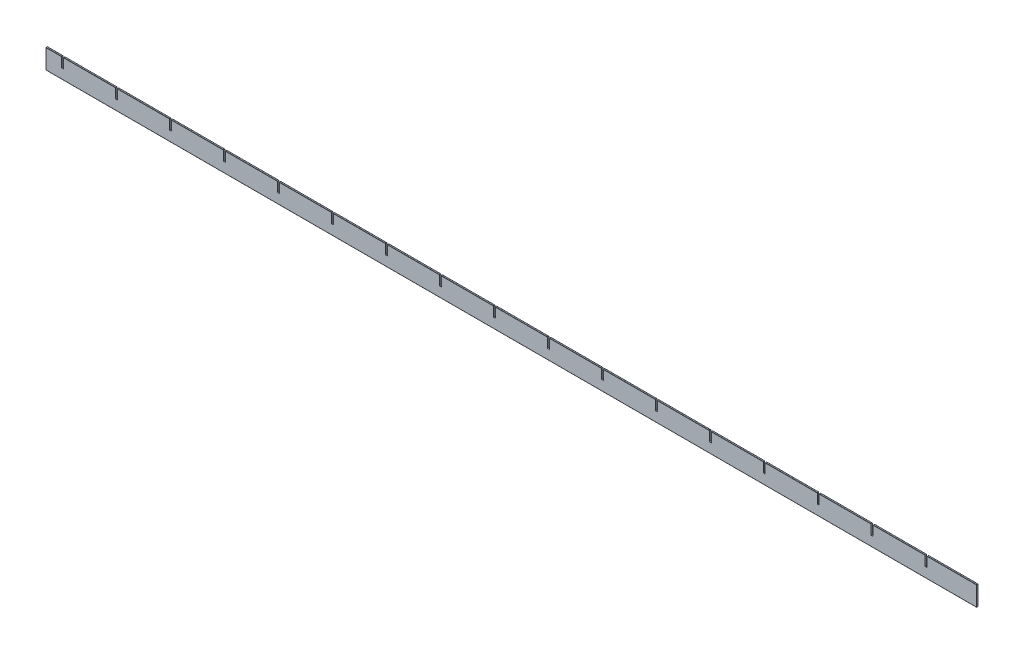
from build123d import *

# Parameters (mm, degrees)
BOSS_EXTRUDE1_DEPTH      = 1.5
BOSS_EXTRUDE1_DEPTH_BACK = 1.5
SKETCH1_W                = 1896
SKETCH1_H                = 40
FILLET1_R                = 0.35
SKETCH2_W                = 4
SKETCH2_H                = 20
CUT_EXTRUDE1_DEPTH       = 949.215692762


with BuildPart() as part:
    # Sketch1 → Boss-Extrude1 (new, two sides: drawn at the far end of the back side and taken through both)
    with BuildSketch(Plane.XY.offset(-BOSS_EXTRUDE1_DEPTH_BACK)):
        Rectangle(SKETCH1_W, SKETCH1_H)
    extrude(amount=BOSS_EXTRUDE1_DEPTH + BOSS_EXTRUDE1_DEPTH_BACK)

    # Fillet1
    fillet1_edges = [part.edges().sort_by_distance(p)[0] for p in [
        (0, -20, -1.5),
        (0, -20, 1.5),
        (0, 20, -1.5),
        (0, 20, 1.5),
    ]]
    fillet(fillet1_edges, radius=FILLET1_R)

    # Sketch2 → Cut-Extrude1 (cut, through all)
    with BuildSketch(Plane.XY.offset(1.5)):
        with Locations((-804.51, 10)):
            Rectangle(SKETCH2_W, SKETCH2_H)
        with Locations((-914.51, 10)):
            Rectangle(SKETCH2_W, SKETCH2_H)
        with Locations((-694.51, 10)):
            Rectangle(SKETCH2_W, SKETCH2_H)
        with Locations((-584.51, 10)):
            Rectangle(SKETCH2_W, SKETCH2_H)
        with Locations((-474.51, 10)):
            Rectangle(SKETCH2_W, SKETCH2_H)
        with Locations((-364.51, 10)):
            Rectangle(SKETCH2_W, SKETCH2_H)
        with Locations((-254.51, 10)):
            Rectangle(SKETCH2_W, SKETCH2_H)
        with Locations((-144.51, 10)):
            Rectangle(SKETCH2_W, SKETCH2_H)
        with Locations((-34.51, 10)):
            Rectangle(SKETCH2_W, SKETCH2_H)
        with Locations((75.49, 10)):
            Rectangle(SKETCH2_W, SKETCH2_H)
        with Locations((185.49, 10)):
            Rectangle(SKETCH2_W, SKETCH2_H)
        with Locations((295.49, 10)):
            Rectangle(SKETCH2_W, SKETCH2_H)
        with Locations((405.49, 10)):
            Rectangle(SKETCH2_W, SKETCH2_H)
        with Locations((515.49, 10)):
            Rectangle(SKETCH2_W, SKETCH2_H)
        with Locations((625.49, 10)):
            Rectangle(SKETCH2_W, SKETCH2_H)
        with Locations((735.49, 10)):
            Rectangle(SKETCH2_W, SKETCH2_H)
        with Locations((845.49, 10)):
            Rectangle(SKETCH2_W, SKETCH2_H)
    extrude(amount=-CUT_EXTRUDE1_DEPTH, mode=Mode.SUBTRACT)


solid = part.part
